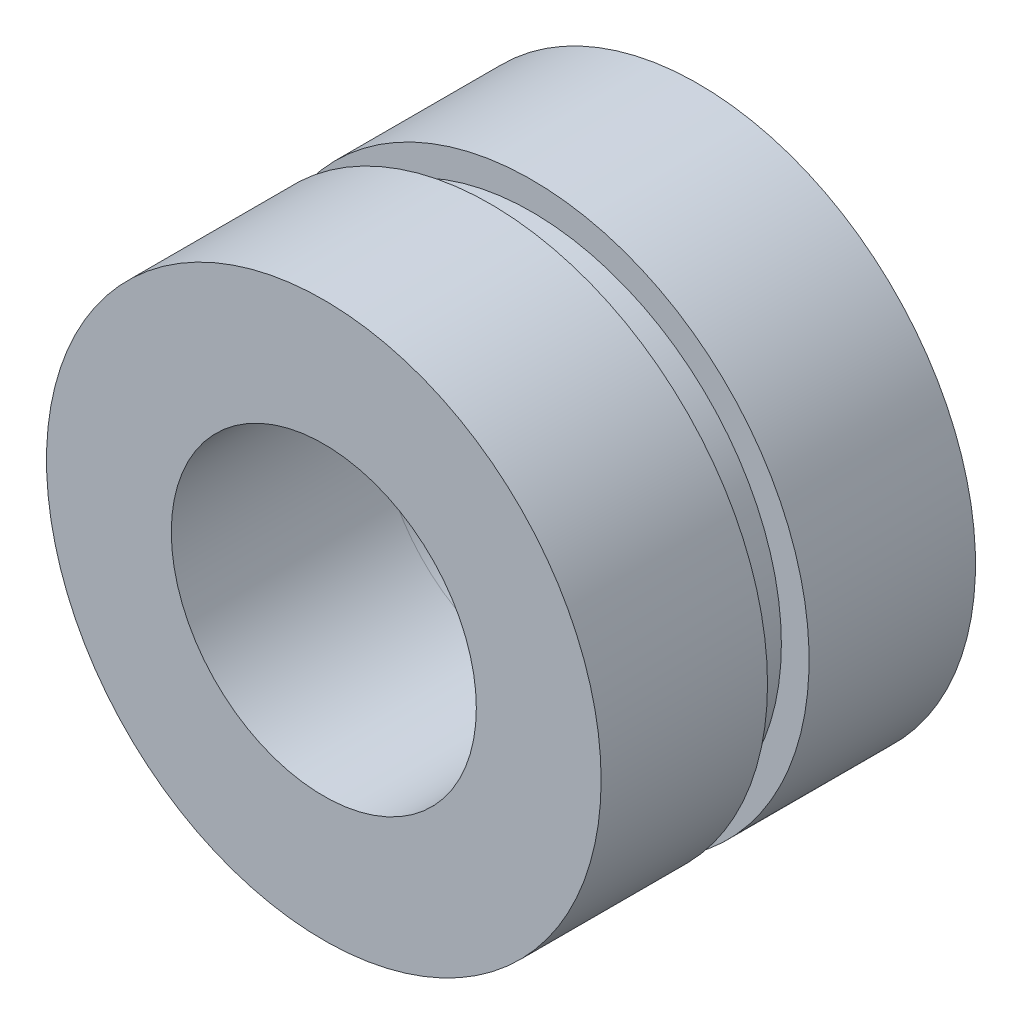
from build123d import *

# Parameters (mm, degrees)
SKETCH1_R           = 4.572
SKETCH1_R_2         = 2.794
BOSS_EXTRUDE2_DEPTH = 0.762
SKETCH3_R           = 5.08
SKETCH3_R_2         = 2.794
BOSS_EXTRUDE3_DEPTH = 3.048
SKETCH4_R           = 5.08
SKETCH4_R_2         = 2.794
BOSS_EXTRUDE4_DEPTH = 3.048


with BuildPart() as part:
    # Sketch1 → Boss-Extrude2 (new body)
    with BuildSketch(Plane.XY):
        Circle(SKETCH1_R)
        Circle(SKETCH1_R_2, mode=Mode.SUBTRACT)
    extrude(amount=BOSS_EXTRUDE2_DEPTH)

    # Sketch3 → Boss-Extrude3 (add)
    with BuildSketch(Plane.XY.offset(0.762)):
        Circle(SKETCH3_R)
        Circle(SKETCH3_R_2, mode=Mode.SUBTRACT)
    extrude(amount=BOSS_EXTRUDE3_DEPTH)


with BuildPart() as body_2:
    # Sketch4 → Boss-Extrude4 (new body)
    with BuildSketch(Plane(origin=(0, 0, 0), x_dir=(-1, 0, 0), z_dir=(0, 0, -1))):
        Circle(SKETCH4_R)
        Circle(SKETCH4_R_2, mode=Mode.SUBTRACT)
    extrude(amount=BOSS_EXTRUDE4_DEPTH)


solid = Compound([part.part, body_2.part])
